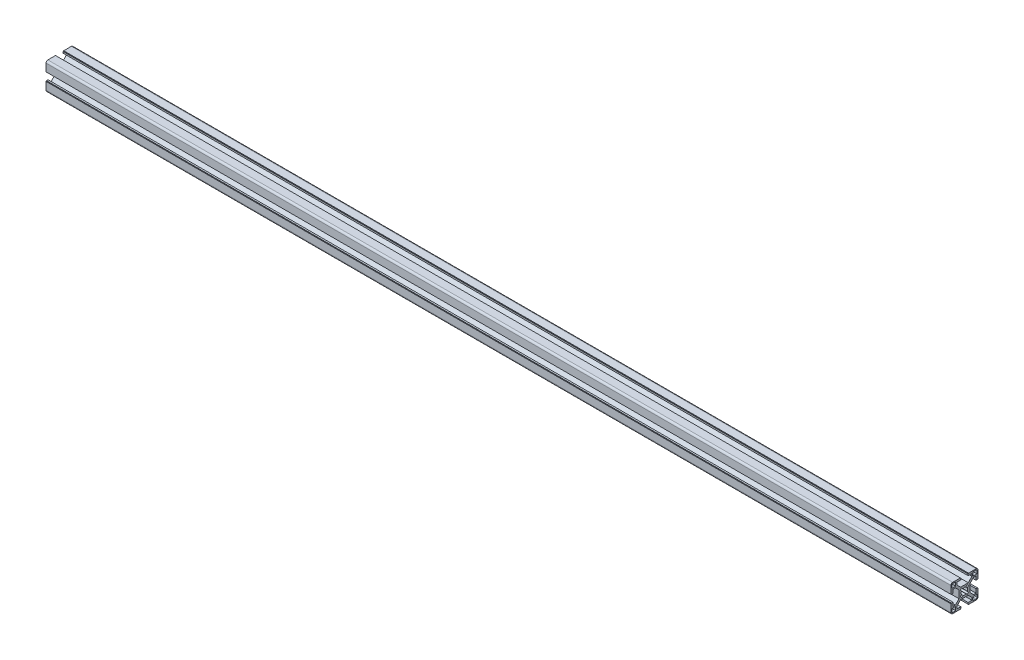
from build123d import *

# Parameters (mm, degrees)
BR_EXTRUDE_DEPTH      = 500
BR_EXTRUDE_DEPTH_BACK = 500


with BuildPart() as part:
    # Sketch2 → BR_Extrude (new, two sides: drawn at the far end of the back side and taken through both)
    with BuildSketch(Plane(origin=(0, 0, 0), x_dir=(0, 0, -1), z_dir=(1, 0, 0)).offset(-BR_EXTRUDE_DEPTH_BACK)):
        with BuildLine():
            Line((-6, 4.196877708), (-10.053122292, 8.25))
            Line((-10.053122292, 8.25), (-12.8, 8.25))
            Line((-12.8, 8.25), (-12.800036742, 4.05))
            Line((-12.800036742, 4.05), (-14.5, 4.05))
            Line((-14.5, 4.05), (-14.5, 4.55))
            Line((-14.5, 4.55), (-15, 4.55))
            Line((-15, 4.55), (-15, 13))
            ThreePointArc((-15, 13), (-14.414213562, 14.414213562), (-13, 15))
            Line((-13, 15), (-4.55, 15))
            Line((-4.55, 15), (-4.55, 14.5))
            Line((-4.55, 14.5), (-4.05, 14.5))
            Line((-4.05, 14.5), (-4.05, 12.800036742))
            Line((-4.05, 12.800036742), (-8.25, 12.8))
            Line((-8.25, 12.8), (-8.25, 10.053122292))
            Line((-8.25, 10.053122292), (-4.196877708, 6))
            Line((-4.196877708, 6), (4.196877708, 6))
            Line((4.196877708, 6), (8.25, 10.053122292))
            Line((8.25, 10.053122292), (8.25, 12.8))
            Line((8.25, 12.8), (4.05, 12.800036742))
            Line((4.05, 12.800036742), (4.05, 14.5))
            Line((4.05, 14.5), (4.55, 14.5))
            Line((4.55, 14.5), (4.55, 15))
            Line((4.55, 15), (13, 15))
            ThreePointArc((13, 15), (14.414213562, 14.414213562), (15, 13))
            Line((15, 13), (15, 4.55))
            Line((15, 4.55), (14.5, 4.55))
            Line((14.5, 4.55), (14.5, 4.05))
            Line((14.5, 4.05), (12.800036742, 4.05))
            Line((12.800036742, 4.05), (12.8, 8.25))
            Line((12.8, 8.25), (10.053122292, 8.25))
            Line((10.053122292, 8.25), (6, 4.196877708))
            Line((6, 4.196877708), (6, -4.196877708))
            Line((6, -4.196877708), (10.053122292, -8.25))
            Line((10.053122292, -8.25), (12.8, -8.25))
            Line((12.8, -8.25), (12.800036742, -4.05))
            Line((12.800036742, -4.05), (14.5, -4.05))
            Line((14.5, -4.05), (14.5, -4.55))
            Line((14.5, -4.55), (15, -4.55))
            Line((15, -4.55), (15, -13))
            ThreePointArc((15, -13), (14.414213562, -14.414213562), (13, -15))
            Line((13, -15), (4.55, -15))
            Line((4.55, -15), (4.55, -14.5))
            Line((4.55, -14.5), (4.05, -14.5))
            Line((4.05, -14.5), (4.05, -12.800036742))
            Line((4.05, -12.800036742), (8.25, -12.8))
            Line((8.25, -12.8), (8.25, -10.053122292))
            Line((8.25, -10.053122292), (4.196877708, -6))
            Line((4.196877708, -6), (-4.196877708, -6))
            Line((-4.196877708, -6), (-8.25, -10.053122292))
            Line((-8.25, -10.053122292), (-8.25, -12.8))
            Line((-8.25, -12.8), (-4.05, -12.800036742))
            Line((-4.05, -12.800036742), (-4.05, -14.5))
            Line((-4.05, -14.5), (-4.55, -14.5))
            Line((-4.55, -14.5), (-4.55, -15))
            Line((-4.55, -15), (-13, -15))
            ThreePointArc((-13, -15), (-14.414213562, -14.414213562), (-15, -13))
            Line((-15, -13), (-15, -4.55))
            Line((-15, -4.55), (-14.5, -4.55))
            Line((-14.5, -4.55), (-14.5, -4.05))
            Line((-14.5, -4.05), (-12.800036742, -4.05))
            Line((-12.800036742, -4.05), (-12.8, -8.25))
            Line((-12.8, -8.25), (-10.053122292, -8.25))
            Line((-10.053122292, -8.25), (-6, -4.196877708))
            Line((-6, -4.196877708), (-6, 4.196877708))
        make_face()
        with BuildLine():
            Line((-13.85, -9.7), (-13.85, -12.85))
            ThreePointArc((-13.85, -12.85), (-13.557106781, -13.557106781), (-12.85, -13.85))
            Line((-12.85, -13.85), (-9.7, -13.85))
            Line((-9.7, -13.85), (-9.7, -9.7))
            Line((-9.7, -9.7), (-13.85, -9.7))
        make_face(mode=Mode.SUBTRACT)
        with BuildLine():
            Line((9.7, -13.85), (12.85, -13.85))
            ThreePointArc((12.85, -13.85), (13.557106781, -13.557106781), (13.85, -12.85))
            Line((13.85, -12.85), (13.85, -9.7))
            Line((13.85, -9.7), (9.7, -9.7))
            Line((9.7, -9.7), (9.7, -13.85))
        make_face(mode=Mode.SUBTRACT)
        with BuildLine():
            Line((13.85, 9.7), (13.85, 12.85))
            ThreePointArc((13.85, 12.85), (13.557106781, 13.557106781), (12.85, 13.85))
            Line((12.85, 13.85), (9.7, 13.85))
            Line((9.7, 13.85), (9.7, 9.7))
            Line((9.7, 9.7), (13.85, 9.7))
        make_face(mode=Mode.SUBTRACT)
        with BuildLine():
            Line((-9.7, 13.85), (-12.85, 13.85))
            ThreePointArc((-12.85, 13.85), (-13.557106781, 13.557106781), (-13.85, 12.85))
            Line((-13.85, 12.85), (-13.85, 9.7))
            Line((-13.85, 9.7), (-9.7, 9.7))
            Line((-9.7, 9.7), (-9.7, 13.85))
        make_face(mode=Mode.SUBTRACT)
        with BuildLine():
            Line((-3.272394192, -1.616767223), (-4.59052283, -3.187651763))
            Line((-4.59052283, -3.187651763), (-3.187651763, -4.59052283))
            Line((-3.187651763, -4.59052283), (-1.616767223, -3.272394192))
            ThreePointArc((-1.616767223, -3.272394192), (0, -3.65), (1.616767223, -3.272394192))
            Line((1.616767223, -3.272394192), (3.187651763, -4.59052283))
            Line((3.187651763, -4.59052283), (4.59052283, -3.187651763))
            Line((4.59052283, -3.187651763), (3.272394192, -1.616767223))
            ThreePointArc((3.272394192, -1.616767223), (3.65, 0), (3.272394192, 1.616767223))
            Line((3.272394192, 1.616767223), (4.59052283, 3.187651763))
            Line((4.59052283, 3.187651763), (3.187651763, 4.59052283))
            Line((3.187651763, 4.59052283), (1.616767223, 3.272394192))
            ThreePointArc((1.616767223, 3.272394192), (0, 3.65), (-1.616767223, 3.272394192))
            Line((-1.616767223, 3.272394192), (-3.187651763, 4.59052283))
            Line((-3.187651763, 4.59052283), (-4.59052283, 3.187651763))
            Line((-4.59052283, 3.187651763), (-3.272394192, 1.616767223))
            ThreePointArc((-3.272394192, 1.616767223), (-3.65, 0), (-3.272394192, -1.616767223))
        make_face(mode=Mode.SUBTRACT)
    extrude(amount=BR_EXTRUDE_DEPTH + BR_EXTRUDE_DEPTH_BACK)


solid = part.part
